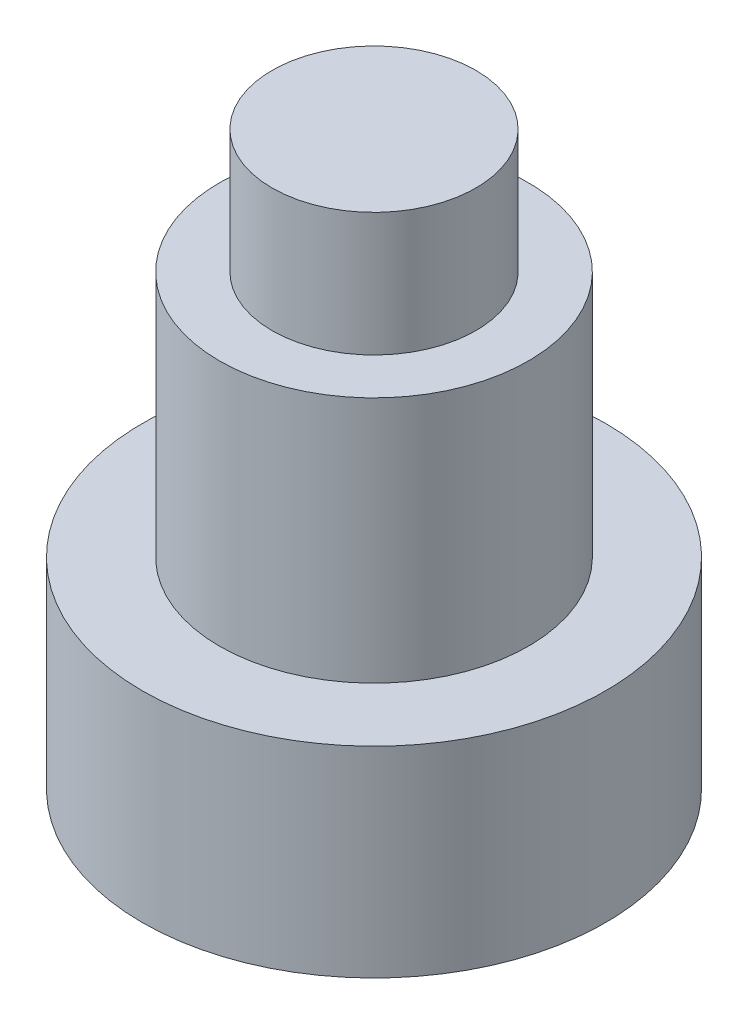
from build123d import *

# Parameters (mm, degrees)
SKETCH1_R           = 3.75
BOSS_EXTRUDE1_DEPTH = 7.25
SKETCH2_R           = 3.75
SKETCH2_R_2         = 2.5
CUT_EXTRUDE1_DEPTH  = 4
SKETCH3_R           = 1.65
BOSS_EXTRUDE2_DEPTH = 2


with BuildPart() as part:
    # Sketch1 → Boss-Extrude1 (new body)
    with BuildSketch(Plane(origin=(0, 0, 0), x_dir=(1, 0, 0), z_dir=(0, 1, 0))):
        Circle(SKETCH1_R)
    extrude(amount=BOSS_EXTRUDE1_DEPTH)

    # Sketch2 → Cut-Extrude1 (cut)
    with BuildSketch(Plane(origin=(0, 7.25, 0), x_dir=(1, 0, 0), z_dir=(0, 1, 0))):
        Circle(SKETCH2_R)
        Circle(SKETCH2_R_2, mode=Mode.SUBTRACT)
    extrude(amount=-CUT_EXTRUDE1_DEPTH, mode=Mode.SUBTRACT)

    # Sketch3 → Boss-Extrude2 (add)
    with BuildSketch(Plane(origin=(0, 7.25, 0), x_dir=(1, 0, 0), z_dir=(0, 1, 0))):
        Circle(SKETCH3_R)
    extrude(amount=BOSS_EXTRUDE2_DEPTH)


solid = part.part
